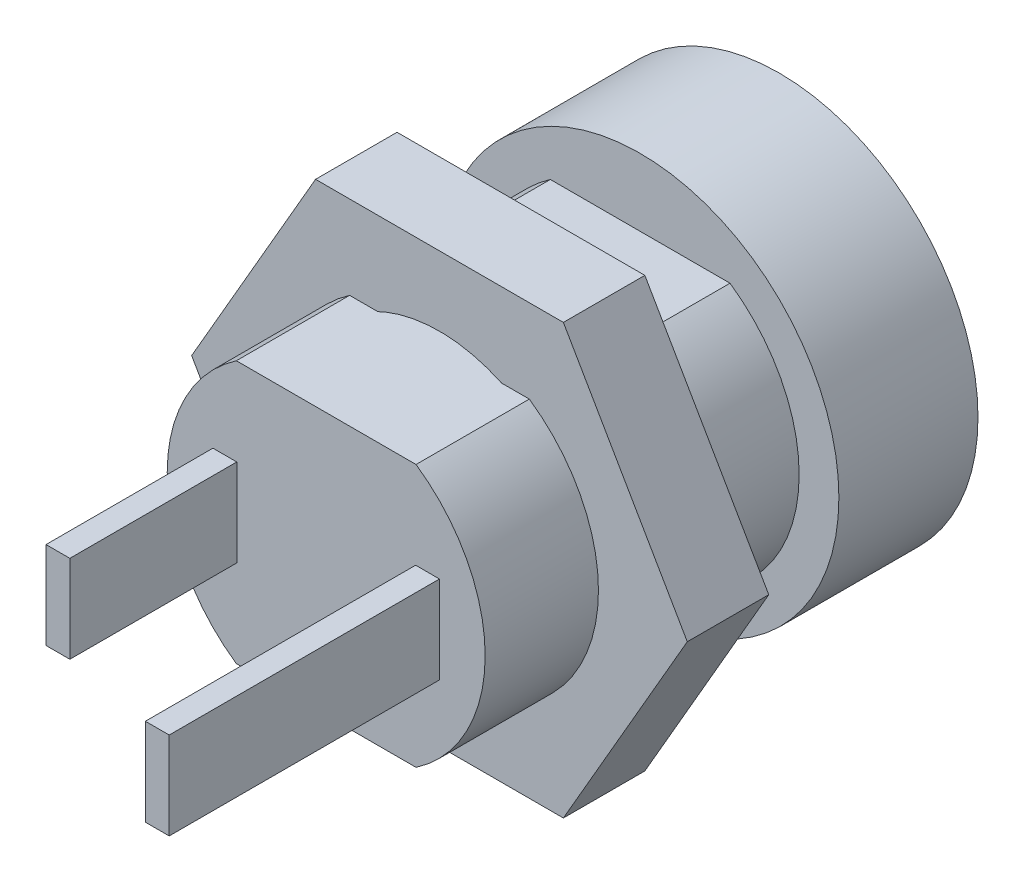
from build123d import *

# Parameters (mm, degrees)
SKETCH_4_W           = 0.6
SKETCH_4_H           = 2.2
EXTRUDE_2_DEPTH      = 4.2
SKETCH_5_W           = 0.6
SKETCH_5_H           = 2.2
EXTRUDE_3_DEPTH      = 2.6
SKETCH_7_R           = 2.75
SKETCH_7_R_2         = 1
CUT_EXTRUDE_2_DEPTH  = 5
SKETCH_8_R           = 5
SKETCH_8_R_2         = 4.45
CUT_EXTRUDE_3_DEPTH  = 0.5
CHAMFER_1_SIZE       = 0.4
SKETCH_9_OUTSIDE_W   = 16.69
SKETCH_9_OUTSIDE_H   = 16.69
SKETCH_9_OUTSIDE_W_2 = 8
SKETCH_9_OUTSIDE_H_2 = 6.6
CUT_EXTRUDE_4_DEPTH  = 7.9
EXTRUDE_START        = 3
SKETCH_10_R          = 3.65
EXTRUDE_4_DEPTH      = 2.05


with BuildPart() as part:
    # Эскиз3 → Повернуть1 (revolve)
    with BuildSketch(Plane(origin=(0, 0, 0), x_dir=(0, 0, -1), z_dir=(1, 0, 0))):
        Polygon((11.9, 0), (11.9, 5), (7.9, 5), (7.9, 4), (0, 4), (0, 0), align=None)
    revolve(axis=Axis((0, 0, 0), (0, 0, -1)))

    # Эскиз4 → Бобышка-Вытянуть2 (add)
    with BuildSketch(Plane.XY):
        with Locations((-2.55, 0)):
            Rectangle(SKETCH_4_W, SKETCH_4_H)
        with Locations((2.55, 0)):
            Rectangle(SKETCH_4_W, SKETCH_4_H)
    extrude(amount=EXTRUDE_2_DEPTH)

    # Эскиз5 → Бобышка-Вытянуть3 (add)
    with BuildSketch(Plane.XY.offset(4.2)):
        with Locations((2.55, 0)):
            Rectangle(SKETCH_5_W, SKETCH_5_H)
    extrude(amount=EXTRUDE_3_DEPTH)

    # Эскиз7 → Вырез-Вытянуть2 (cut)
    with BuildSketch(Plane(origin=(0, 0, -11.9), x_dir=(-1, 0, 0), z_dir=(0, 0, -1))):
        Circle(SKETCH_7_R)
        Circle(SKETCH_7_R_2, mode=Mode.SUBTRACT)
    extrude(amount=-CUT_EXTRUDE_2_DEPTH, mode=Mode.SUBTRACT)

    # Эскиз8 → Вырез-Вытянуть3 (cut)
    with BuildSketch(Plane(origin=(0, 0, -11.9), x_dir=(-1, 0, 0), z_dir=(0, 0, -1))):
        Circle(SKETCH_8_R)
        Circle(SKETCH_8_R_2, mode=Mode.SUBTRACT)
    extrude(amount=-CUT_EXTRUDE_3_DEPTH, mode=Mode.SUBTRACT)

    # Фаска1
    chamfer_1_edges = [part.edges().sort_by_distance(p)[0] for p in [
        (4.45, 0, -11.9),
    ]]
    chamfer(chamfer_1_edges, length=CHAMFER_1_SIZE)

    # Эскиз9 outside → Вырез-Вытянуть4 (cut)
    with BuildSketch(Plane.XY):
        Rectangle(SKETCH_9_OUTSIDE_W, SKETCH_9_OUTSIDE_H)
        Rectangle(SKETCH_9_OUTSIDE_W_2, SKETCH_9_OUTSIDE_H_2, mode=Mode.SUBTRACT)
    extrude(amount=-CUT_EXTRUDE_4_DEPTH, mode=Mode.SUBTRACT)


with BuildPart() as body_2:
    # Эскиз10 → Бобышка-Вытянуть4 (new body)
    with BuildSketch(Plane.XY.offset(-7.9).offset(EXTRUDE_START)):
        Polygon((-6.235382907, 0), (-3.117691454, -5.4), (3.117691454, -5.4), (6.235382907, 0), (3.117691454, 5.4), (-3.117691454, 5.4), align=None)
        Circle(SKETCH_10_R, mode=Mode.SUBTRACT)
    extrude(amount=EXTRUDE_4_DEPTH)


solid = Compound([part.part, body_2.part])
